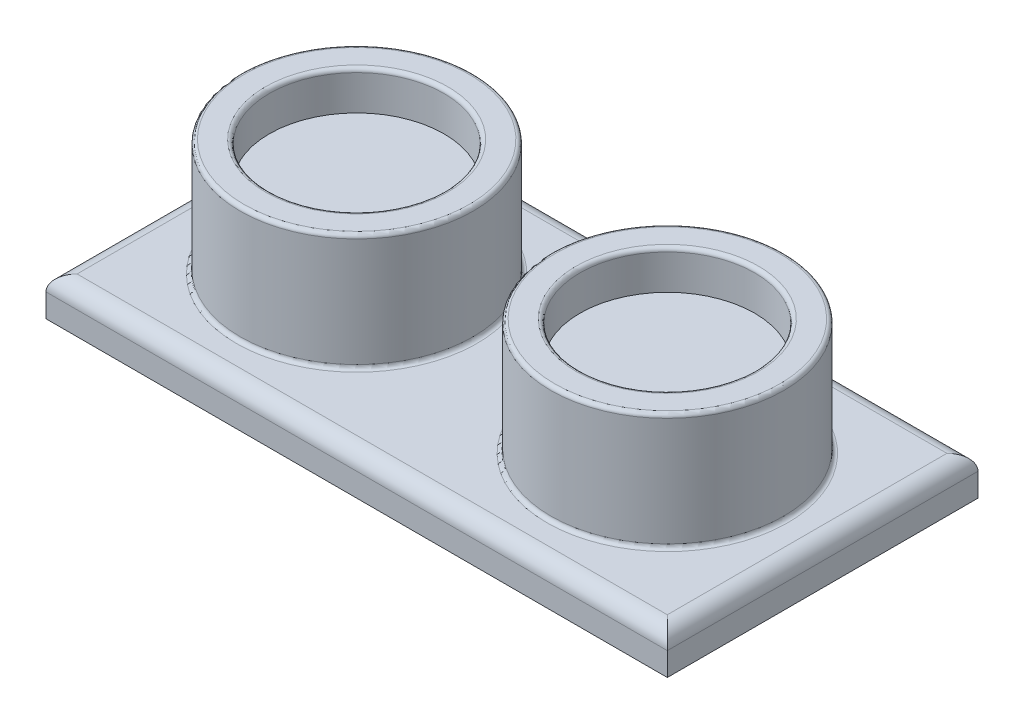
from build123d import *

# Parameters (mm, degrees)
SKETCH1_W           = 80
SKETCH1_H           = 40
BOSS_EXTRUDE1_DEPTH = 5
SKETCH2_R           = 15
BOSS_EXTRUDE2_DEPTH = 15
SKETCH3_R           = 11.25
CUT_EXTRUDE1_DEPTH  = 5
FILLET1_R           = 2
FILLET2_R           = 0.5


with BuildPart() as part:
    # Sketch1 → Boss-Extrude1 (new body)
    with BuildSketch(Plane(origin=(0, 0, 0), x_dir=(1, 0, 0), z_dir=(0, 1, 0))):
        Rectangle(SKETCH1_W, SKETCH1_H)
    extrude(amount=BOSS_EXTRUDE1_DEPTH)

    # Sketch2 → Boss-Extrude2 (add)
    with BuildSketch(Plane(origin=(0, 5, 0), x_dir=(1, 0, 0), z_dir=(0, 1, 0))):
        with Locations((-20, 0)):
            Circle(SKETCH2_R)
        with Locations((20, 0)):
            Circle(SKETCH2_R)
    extrude(amount=BOSS_EXTRUDE2_DEPTH)

    # Sketch3 → Cut-Extrude1 (cut)
    with BuildSketch(Plane(origin=(0, 20, 0), x_dir=(1, 0, 0), z_dir=(0, 1, 0))):
        with Locations((-20, 0)):
            Circle(SKETCH3_R)
        with Locations((20, 0)):
            Circle(SKETCH3_R)
    extrude(amount=-CUT_EXTRUDE1_DEPTH, mode=Mode.SUBTRACT)

    # Fillet1
    fillet1_edges = [part.edges().sort_by_distance(p)[0] for p in [
        (-40, 5, 0),
        (0, 5, 20),
        (40, 5, 0),
        (0, 5, -20),
    ]]
    fillet(fillet1_edges, radius=FILLET1_R)

    # Fillet2
    fillet2_edges = [part.edges().sort_by_distance(p)[0] for p in [
        (-35, 5, 0),
        (-35, 20, 0),
        (5, 5, 0),
        (5, 20, 0),
        (-31.25, 20, 0),
        (8.75, 20, 0),
    ]]
    fillet(fillet2_edges, radius=FILLET2_R)


solid = part.part
